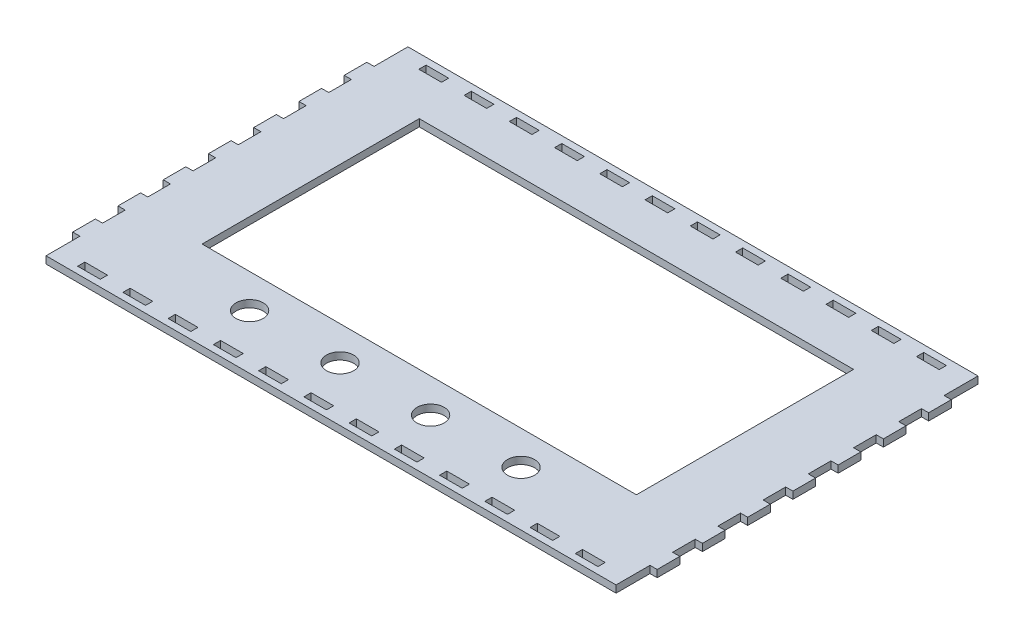
from build123d import *

# Parameters (mm, degrees)
SKETCH1_R           = 6
SKETCH1_W           = 10
SKETCH1_H           = 3.175
SKETCH1_W_2         = 192
SKETCH1_H_2         = 96
BOSS_EXTRUDE1_DEPTH = 3.175


with BuildPart() as part:
    # Sketch1 → Boss-Extrude1 (new body)
    with BuildSketch(Plane(origin=(0, 0, 0), x_dir=(1, 0, 0), z_dir=(0, 1, 0))):
        Polygon((0, 145), (0, 160), (252, 160), (252, 145), (255.175, 145), (255.175, 135), (252, 135), (252, 125), (255.175, 125), (255.175, 115), (252, 115), (252, 105), (255.175, 105), (255.175, 95), (252, 95), (252, 85), (255.175, 85), (255.175, 75), (252, 75), (252, 65), (255.175, 65), (255.175, 55), (252, 55), (252, 45), (255.175, 45), (255.175, 35), (252, 35), (252, 25), (255.175, 25), (255.175, 15), (252, 15), (252, 0), (0, 0), (0, 15), (-3.175, 15), (-3.175, 25), (0, 25), (0, 35), (-3.175, 35), (-3.175, 45), (0, 45), (0, 55), (-3.175, 55), (-3.175, 65), (0, 65), (0, 75), (-3.175, 75), (-3.175, 85), (0, 85), (0, 95), (-3.175, 95), (-3.175, 105), (0, 105), (0, 115), (-3.175, 115), (-3.175, 125), (0, 125), (0, 135), (-3.175, 135), (-3.175, 145), align=None)
        with Locations((106, 24)):
            Circle(SKETCH1_R, mode=Mode.SUBTRACT)
        with Locations((66, 24)):
            Circle(SKETCH1_R, mode=Mode.SUBTRACT)
        with Locations((186, 24)):
            Circle(SKETCH1_R, mode=Mode.SUBTRACT)
        with Locations((146, 24)):
            Circle(SKETCH1_R, mode=Mode.SUBTRACT)
        with Locations((36, 155.4125)):
            Rectangle(SKETCH1_W, SKETCH1_H, mode=Mode.SUBTRACT)
        with Locations((126, 87)):
            Rectangle(SKETCH1_W_2, SKETCH1_H_2, mode=Mode.SUBTRACT)
        with Locations((16, 155.4125)):
            Rectangle(SKETCH1_W, SKETCH1_H, mode=Mode.SUBTRACT)
        with Locations((56, 155.4125)):
            Rectangle(SKETCH1_W, SKETCH1_H, mode=Mode.SUBTRACT)
        with Locations((76, 155.4125)):
            Rectangle(SKETCH1_W, SKETCH1_H, mode=Mode.SUBTRACT)
        with Locations((96, 155.4125)):
            Rectangle(SKETCH1_W, SKETCH1_H, mode=Mode.SUBTRACT)
        with Locations((116, 155.4125)):
            Rectangle(SKETCH1_W, SKETCH1_H, mode=Mode.SUBTRACT)
        with Locations((136, 155.4125)):
            Rectangle(SKETCH1_W, SKETCH1_H, mode=Mode.SUBTRACT)
        with Locations((156, 155.4125)):
            Rectangle(SKETCH1_W, SKETCH1_H, mode=Mode.SUBTRACT)
        with Locations((176, 155.4125)):
            Rectangle(SKETCH1_W, SKETCH1_H, mode=Mode.SUBTRACT)
        with Locations((196, 155.4125)):
            Rectangle(SKETCH1_W, SKETCH1_H, mode=Mode.SUBTRACT)
        with Locations((216, 155.4125)):
            Rectangle(SKETCH1_W, SKETCH1_H, mode=Mode.SUBTRACT)
        with Locations((236, 155.4125)):
            Rectangle(SKETCH1_W, SKETCH1_H, mode=Mode.SUBTRACT)
        with Locations((236, 4.5875)):
            Rectangle(SKETCH1_W, SKETCH1_H, mode=Mode.SUBTRACT)
        with Locations((216, 4.5875)):
            Rectangle(SKETCH1_W, SKETCH1_H, mode=Mode.SUBTRACT)
        with Locations((196, 4.5875)):
            Rectangle(SKETCH1_W, SKETCH1_H, mode=Mode.SUBTRACT)
        with Locations((176, 4.5875)):
            Rectangle(SKETCH1_W, SKETCH1_H, mode=Mode.SUBTRACT)
        with Locations((156, 4.5875)):
            Rectangle(SKETCH1_W, SKETCH1_H, mode=Mode.SUBTRACT)
        with Locations((136, 4.5875)):
            Rectangle(SKETCH1_W, SKETCH1_H, mode=Mode.SUBTRACT)
        with Locations((116, 4.5875)):
            Rectangle(SKETCH1_W, SKETCH1_H, mode=Mode.SUBTRACT)
        with Locations((96, 4.5875)):
            Rectangle(SKETCH1_W, SKETCH1_H, mode=Mode.SUBTRACT)
        with Locations((76, 4.5875)):
            Rectangle(SKETCH1_W, SKETCH1_H, mode=Mode.SUBTRACT)
        with Locations((56, 4.5875)):
            Rectangle(SKETCH1_W, SKETCH1_H, mode=Mode.SUBTRACT)
        with Locations((36, 4.5875)):
            Rectangle(SKETCH1_W, SKETCH1_H, mode=Mode.SUBTRACT)
        with Locations((16, 4.5875)):
            Rectangle(SKETCH1_W, SKETCH1_H, mode=Mode.SUBTRACT)
    extrude(amount=BOSS_EXTRUDE1_DEPTH)


solid = part.part
